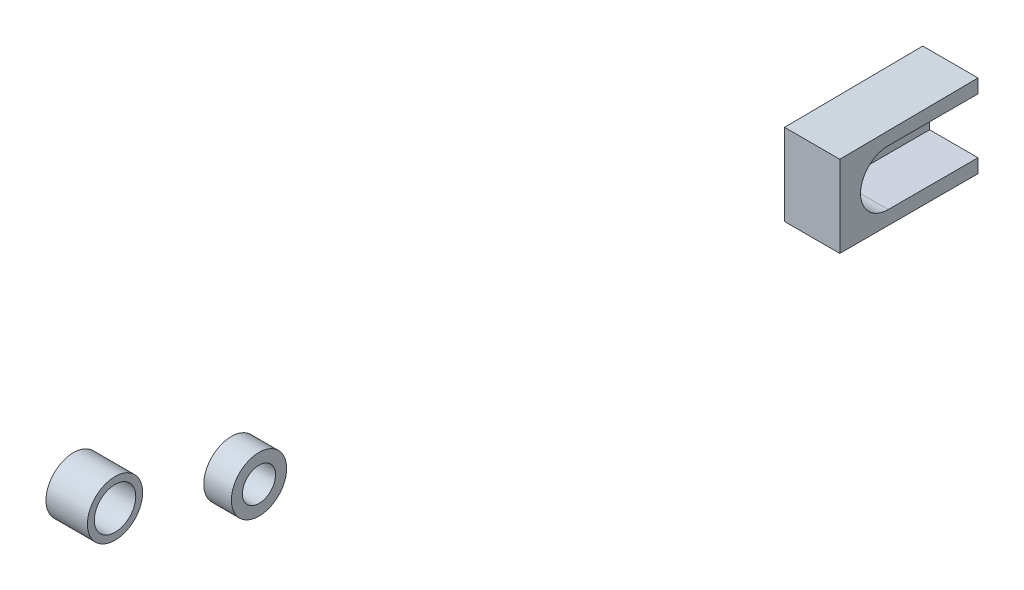
from build123d import *

# Parameters (mm, degrees)
TYLNE_START              = -7.5
TYLNE_KO_O_DEPTH         = 5
TYLENE_START             = -2.5
TYLENE_KO_O_2_DEPTH      = 35
RAMA_START               = -50
SZKIC_INSERT_RAMA_R      = 20
SZKIC_INSERT_RAMA_R_2    = 15
RAMA_DEPTH               = 30
LINKAGE_START            = 25
SZKIC_INSERT_LINKAGE_R   = 20
SZKIC_INSERT_LINKAGE_R_2 = 12
LINKAGE_DEPTH            = 20


with BuildPart() as part:
    # Szkic - insert - tylne koło → Tylne koło (new body)
    with BuildSketch(Plane(origin=(125, 0, 0), x_dir=(0, 0, -1), z_dir=(1, 0, 0)).offset(TYLNE_START)):
        with BuildLine():
            ThreePointArc((487, 20), (467, 0), (487, -20))
            Line((487, -20), (552, -20))
            Line((552, -20), (552, -30))
            Line((552, -30), (452, -30))
            Line((452, -30), (452, 29.044549731))
            Line((452, 29.044549731), (552, 30))
            Line((552, 30), (552, 20))
            Line((552, 20), (487, 20))
        make_face()
        with BuildLine():
            Line((487, 20), (552, 20))
            Line((552, 20), (552, -20))
            Line((552, -20), (487, -20))
            ThreePointArc((487, -20), (467, 0), (487, 20))
        make_face()
        with BuildLine():
            ThreePointArc((537, -8), (545, 0), (537, 8))
            Line((537, 8), (487, 8))
            ThreePointArc((487, 8), (479, 0), (487, -8))
            Line((487, -8), (537, -8))
        make_face(mode=Mode.SUBTRACT)
    extrude(amount=TYLNE_KO_O_DEPTH)

    # Szkic - insert - tylne koło<6> → Tylene koło 2 (add)
    with BuildSketch(Plane(origin=(125, 0, 0), x_dir=(0, 0, -1), z_dir=(1, 0, 0)).offset(TYLENE_START)):
        with BuildLine():
            ThreePointArc((487, 20), (467, 0), (487, -20))
            Line((487, -20), (552, -20))
            Line((552, -20), (552, -30))
            Line((552, -30), (452, -30))
            Line((452, -30), (452, 29.044549731))
            Line((452, 29.044549731), (552, 30))
            Line((552, 30), (552, 20))
            Line((552, 20), (487, 20))
        make_face()
    extrude(amount=TYLENE_KO_O_2_DEPTH)


with BuildPart() as body_2:
    # Szkic - insert - rama → Rama (new body)
    with BuildSketch(Plane(origin=(135, 0, 0), x_dir=(0, 0, -1), z_dir=(1, 0, 0)).offset(RAMA_START)):
        Circle(SZKIC_INSERT_RAMA_R)
        Circle(SZKIC_INSERT_RAMA_R_2, mode=Mode.SUBTRACT)
    extrude(amount=-RAMA_DEPTH)


with BuildPart() as body_3:
    # Szkic - insert - linkage → Linkage (new body)
    with BuildSketch(Plane(origin=(0, 0, 0), x_dir=(0, 0, -1), z_dir=(1, 0, 0)).offset(LINKAGE_START)):
        with Locations((144.2, -77)):
            Circle(SZKIC_INSERT_LINKAGE_R)
        with Locations((144.2, -77)):
            Circle(SZKIC_INSERT_LINKAGE_R_2, mode=Mode.SUBTRACT)
    extrude(amount=LINKAGE_DEPTH)


solid = Compound([part.part, body_2.part, body_3.part])
